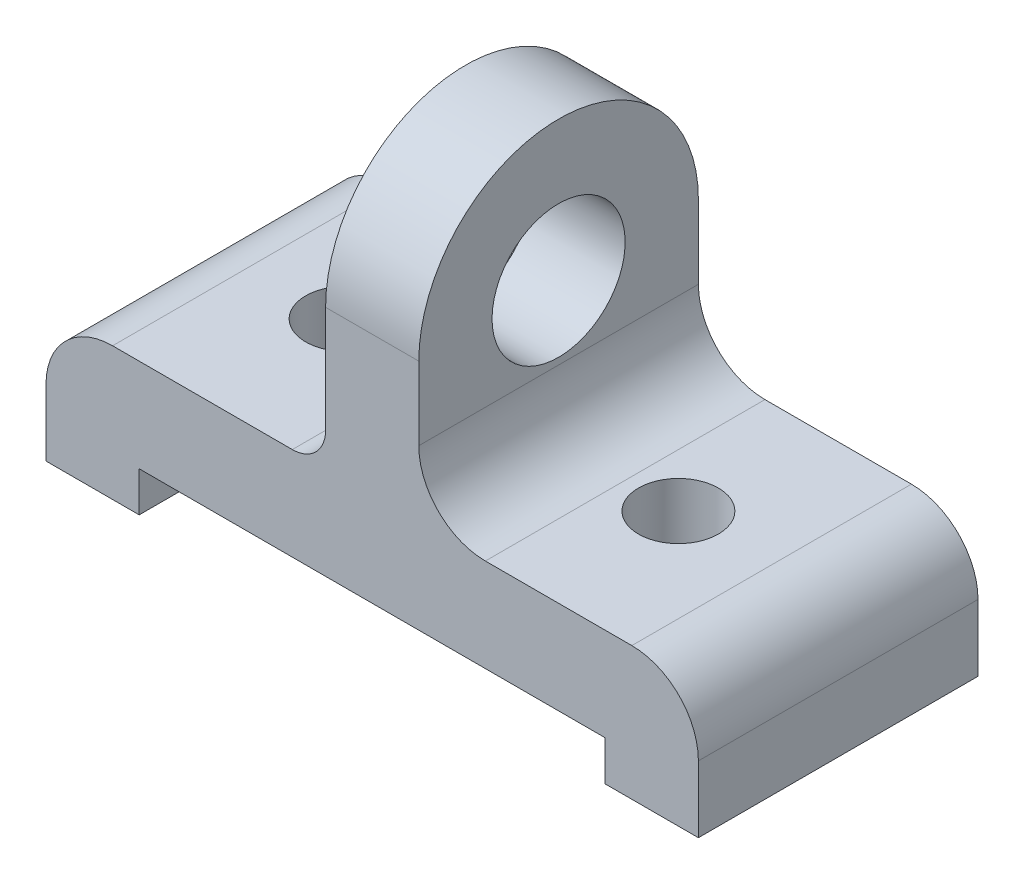
from build123d import *

# Parameters (mm, degrees)
SKETCH2_W           = 98
SKETCH2_H           = 42
SKETCH2_R           = 6
BOSS_EXTRUDE1_DEPTH = 20
SKETCH3_W           = 70
SKETCH3_H           = 6
CUT_EXTRUDE2_DEPTH  = 20
SKETCH4_W           = 70
SKETCH4_H           = 6
CUT_EXTRUDE3_DEPTH  = 20
SKETCH5_W           = 4.083920217
SKETCH5_H           = 6
CUT_EXTRUDE4_DEPTH  = 20
SKETCH6_W           = 4.083920217
SKETCH6_H           = 6
CUT_EXTRUDE5_DEPTH  = 20
SKETCH7_W           = 38.167840434
SKETCH7_H           = 6
CUT_EXTRUDE6_DEPTH  = 20
SKETCH8_R           = 10
BOSS_EXTRUDE2_DEPTH = 7
FILLET2_R           = 5
FILLET3_R           = 10


with BuildPart() as part:
    # Sketch2 → Boss-Extrude1 (new body)
    with BuildSketch(Plane(origin=(0, 0, 0), x_dir=(1, 0, 0), z_dir=(0, 1, 0))):
        Rectangle(SKETCH2_W, SKETCH2_H)
        with Locations((25, 0)):
            Circle(SKETCH2_R, mode=Mode.SUBTRACT)
        with Locations((-25, 0)):
            Circle(SKETCH2_R, mode=Mode.SUBTRACT)
    extrude(amount=-BOSS_EXTRUDE1_DEPTH)

    # Sketch3 → Cut-Extrude2 (cut)
    with BuildSketch(Plane.XY.offset(21)):
        with Locations((0, -17)):
            Rectangle(SKETCH3_W, SKETCH3_H)
    extrude(amount=-CUT_EXTRUDE2_DEPTH, mode=Mode.SUBTRACT)

    # Sketch4 → Cut-Extrude3 (cut)
    with BuildSketch(Plane(origin=(0, 0, -21), x_dir=(-1, 0, 0), z_dir=(0, 0, -1))):
        with Locations((0, -17)):
            Rectangle(SKETCH4_W, SKETCH4_H)
    extrude(amount=-CUT_EXTRUDE3_DEPTH, mode=Mode.SUBTRACT)

    # Sketch5 → Cut-Extrude4 (cut)
    with BuildSketch(Plane.XY.offset(1)):
        with Locations((32.958039892, -17)):
            Rectangle(SKETCH5_W, SKETCH5_H)
    extrude(amount=-CUT_EXTRUDE4_DEPTH, mode=Mode.SUBTRACT)

    # Sketch6 → Cut-Extrude5 (cut)
    with BuildSketch(Plane.XY.offset(1)):
        with Locations((-32.958039892, -17)):
            Rectangle(SKETCH6_W, SKETCH6_H)
    extrude(amount=-CUT_EXTRUDE5_DEPTH, mode=Mode.SUBTRACT)

    # Sketch7 → Cut-Extrude6 (cut)
    with BuildSketch(Plane.XY.offset(1)):
        with Locations((0, -17)):
            Rectangle(SKETCH7_W, SKETCH7_H)
    extrude(amount=-CUT_EXTRUDE6_DEPTH, mode=Mode.SUBTRACT)

    # Sketch8 → Boss-Extrude2 (add, symmetric)
    with BuildSketch(Plane.ZY):
        with BuildLine():
            Line((-21, 0), (21, 0))
            Line((21, 0), (21, 21))
            ThreePointArc((21, 21), (0, 42), (-21, 21))
            Line((-21, 21), (-21, 0))
        make_face()
        with Locations((0, 21)):
            Circle(SKETCH8_R, mode=Mode.SUBTRACT)
    extrude(amount=BOSS_EXTRUDE2_DEPTH, both=True)

    # Fillet2
    fillet2_edges = [part.edges().sort_by_distance(p)[0] for p in [
        (-7, 0, 0),
    ]]
    fillet(fillet2_edges, radius=FILLET2_R)

    # Fillet3
    fillet3_edges = [part.edges().sort_by_distance(p)[0] for p in [
        (7, 0, 0),
        (-49, 0, 0),
        (49, 0, 0),
    ]]
    fillet(fillet3_edges, radius=FILLET3_R)


solid = part.part
